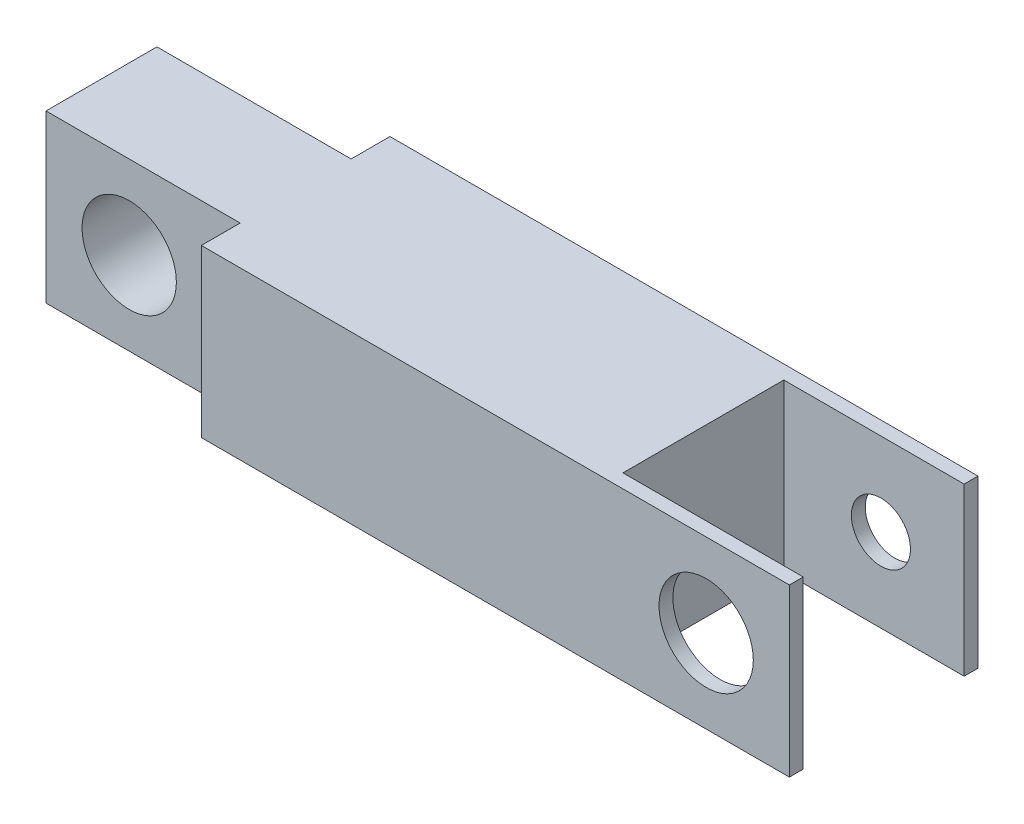
from build123d import *

# Parameters (mm, degrees)
SKETCH1_W                 = 35.814
SKETCH1_H                 = 7.62
BOSS_EXTRUDE1_DEPTH       = 8.636
SKETCH4_W                 = 8.89
SKETCH4_H                 = 1.778
CUT_EXTRUDE1_DEPTH        = 8.62
SKETCH6_W                 = 8.255
SKETCH6_H                 = 7.366
CUT_EXTRUDE2_DEPTH        = 8.62
SKETCH7_R                 = 2.159
CUT_EXTRUDE3_DEPTH        = 7.858
CUT_EXTRUDE4_REACH        = 10.636
SKETCH8_R                 = 2.159
F_6_32_TAPPED_HOLE1_D     = 2.7051
F_6_32_TAPPED_HOLE1_DEPTH = 0.635


with BuildPart() as part:
    # Sketch1 → Boss-Extrude1 (new body)
    with BuildSketch(Plane.XY):
        with Locations((-21.190085106, 0.628244681)):
            Rectangle(SKETCH1_W, SKETCH1_H)
    extrude(amount=BOSS_EXTRUDE1_DEPTH)

    # Sketch4 → Cut-Extrude1 (cut, through all)
    with BuildSketch(Plane(origin=(0, 4.438244681, 0), x_dir=(1, 0, 0), z_dir=(0, 1, 0))):
        with Locations((-34.652085106, -0.889)):
            Rectangle(SKETCH4_W, SKETCH4_H)
        with Locations((-34.652085106, -7.747)):
            Rectangle(SKETCH4_W, SKETCH4_H)
    extrude(amount=-CUT_EXTRUDE1_DEPTH, mode=Mode.SUBTRACT)

    # Sketch6 → Cut-Extrude2 (cut, through all)
    with BuildSketch(Plane(origin=(0, 4.438244681, 0), x_dir=(1, 0, 0), z_dir=(0, 1, 0))):
        with Locations((-7.410585106, -4.318)):
            Rectangle(SKETCH6_W, SKETCH6_H)
    extrude(amount=-CUT_EXTRUDE2_DEPTH, mode=Mode.SUBTRACT)

    # Sketch7 → Cut-Extrude3 (cut, through all)
    with BuildSketch(Plane.XY.offset(6.858)):
        with Locations((-35.287085106, 0.628244681)):
            Circle(SKETCH7_R)
    extrude(amount=-CUT_EXTRUDE3_DEPTH, mode=Mode.SUBTRACT)

    # Sketch8 → Cut-Extrude4 (cut, up to next)
    with BuildSketch(Plane.XY.offset(8.636), mode=Mode.PRIVATE) as cut_extrude4_sk1:
        with Locations((-7.093085106, 0.628244681)):
            Circle(SKETCH8_R)
    cut_extrude4_tool1 = extrude(cut_extrude4_sk1.sketch, amount=-CUT_EXTRUDE4_REACH, mode=Mode.PRIVATE) & part.part
    add(cut_extrude4_tool1.solids().sort_by_distance((-7.093085, 0.628245, 8.636))[0], mode=Mode.SUBTRACT)

    # #6-32 Tapped Hole1
    with Locations(Plane(origin=(0, 0, 0), x_dir=(-1, 0, 0), z_dir=(0, 0, -1))):
        with Locations((7.093085106, 0.628244681)):
            Hole(F_6_32_TAPPED_HOLE1_D / 2, depth=F_6_32_TAPPED_HOLE1_DEPTH)


solid = part.part
